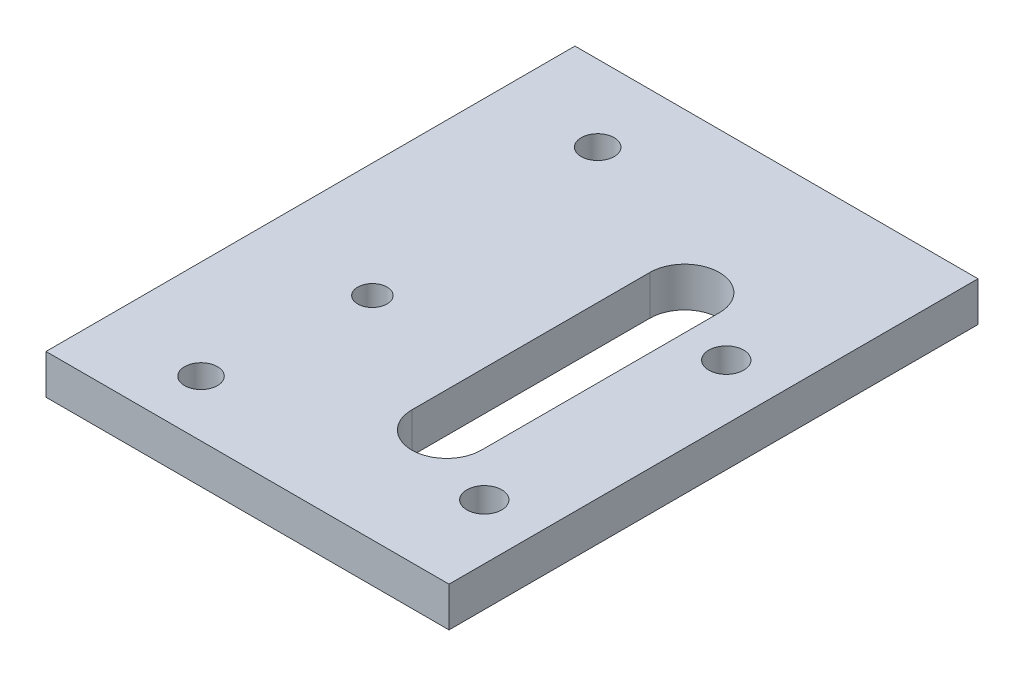
from build123d import *

# Parameters (mm, degrees)
SKETCH1_W           = 50.8
SKETCH1_H           = 66.675
BOSS_EXTRUDE1_DEPTH = 5
SKETCH2_R           = 2.075
SKETCH2_R_2         = 1.85
CUT_EXTRUDE1_DEPTH  = 6
CUT_EXTRUDE2_REACH  = 7
SKETCH3_R           = 2.2
CUT_EXTRUDE3_REACH  = 7


with BuildPart() as part:
    # Sketch1 → Boss-Extrude1 (new body)
    with BuildSketch(Plane(origin=(0, 0, 0), x_dir=(1, 0, 0), z_dir=(0, 1, 0))):
        with Locations((25.4, 33.3375)):
            Rectangle(SKETCH1_W, SKETCH1_H)
    extrude(amount=BOSS_EXTRUDE1_DEPTH)

    # Sketch2 → Cut-Extrude1 (cut, through all)
    with BuildSketch(Plane(origin=(0, 5, 0), x_dir=(1, 0, 0), z_dir=(0, 1, 0))):
        with Locations(Location((12.465, 57.075, 0), (0, 0, 270))):  # turned: the seam where the file's is
            Circle(SKETCH2_R)
        with Locations(Location((12.465, 7.075, 0), (0, 0, 270))):  # turned: the seam where the file's is
            Circle(SKETCH2_R)
        with Locations(Location((14.465, 26.675, 0), (0, 0, 270))):  # turned: the seam where the file's is
            Circle(SKETCH2_R_2)
    extrude(amount=-CUT_EXTRUDE1_DEPTH, mode=Mode.SUBTRACT)

    # Sketch3 → Cut-Extrude2 (cut, up to next)
    with BuildSketch(Plane(origin=(0, 5, 0), x_dir=(1, 0, 0), z_dir=(0, 1, 0)), mode=Mode.PRIVATE) as cut_extrude2_sk1:
        with Locations(Location((43.82, 41.925, 0), (0, 0, 270))):  # turned: the seam where the file's is
            Circle(SKETCH3_R)
    cut_extrude2_tool1 = extrude(cut_extrude2_sk1.sketch, amount=-CUT_EXTRUDE2_REACH, mode=Mode.PRIVATE) & part.part
    add(cut_extrude2_tool1.solids().sort_by_distance((43.82, 5, -41.925))[0], mode=Mode.SUBTRACT)
    # Sketch3 → Cut-Extrude2 (cut, up to next)
    with BuildSketch(Plane(origin=(0, 5, 0), x_dir=(1, 0, 0), z_dir=(0, 1, 0)), mode=Mode.PRIVATE) as cut_extrude2_sk2:
        with Locations(Location((43.82, 11.425, 0), (0, 0, 270))):  # turned: the seam where the file's is
            Circle(SKETCH3_R)
    cut_extrude2_tool2 = extrude(cut_extrude2_sk2.sketch, amount=-CUT_EXTRUDE2_REACH, mode=Mode.PRIVATE) & part.part
    add(cut_extrude2_tool2.solids().sort_by_distance((43.82, 5, -11.425))[0], mode=Mode.SUBTRACT)

    # Sketch4 → Cut-Extrude3 (cut, up to next)
    with BuildSketch(Plane(origin=(0, 5, 0), x_dir=(1, 0, 0), z_dir=(0, 1, 0)), mode=Mode.PRIVATE) as cut_extrude3_sk1:
        with BuildLine():
            Line((38.21, 46.675), (38.21, 16.675))
            ThreePointArc((38.21, 16.675), (33.82, 12.285), (29.43, 16.675))
            Line((29.43, 16.675), (29.43, 46.675))
            ThreePointArc((29.43, 46.675), (33.82, 51.065), (38.21, 46.675))
        make_face()
    cut_extrude3_tool1 = extrude(cut_extrude3_sk1.sketch, amount=-CUT_EXTRUDE3_REACH, mode=Mode.PRIVATE) & part.part
    add(cut_extrude3_tool1.solids().sort_by_distance((33.82, 5, -31.675))[0], mode=Mode.SUBTRACT)


solid = part.part
